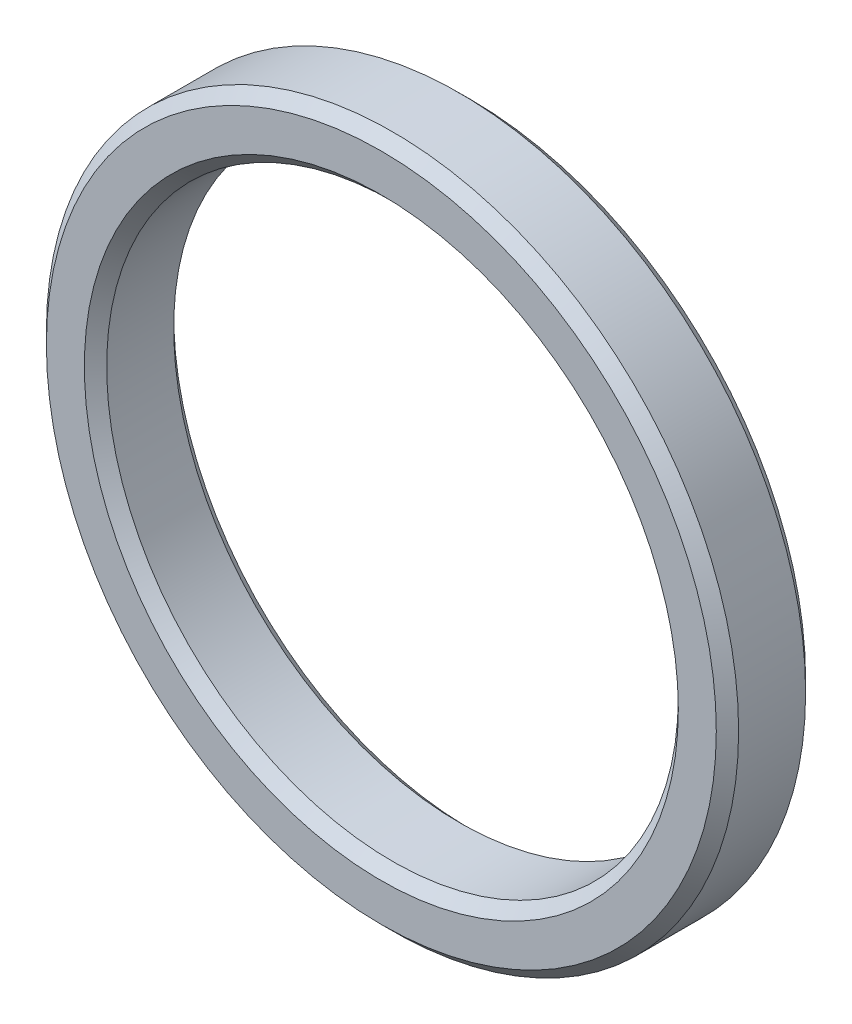
from build123d import *

# Parameters (mm, degrees)
SKETCH1_R           = 15.5
SKETCH1_R_2         = 12.8
BOSS_EXTRUDE1_DEPTH = 4
CHAMFER1_SIZE       = 0.5


with BuildPart() as part:
    # Sketch1 → Boss-Extrude1 (new body)
    with BuildSketch(Plane.XY):
        Circle(SKETCH1_R)
        Circle(SKETCH1_R_2, mode=Mode.SUBTRACT)
    extrude(amount=BOSS_EXTRUDE1_DEPTH)

    # Chamfer1
    chamfer1_edges = [part.edges().sort_by_distance(p)[0] for p in [
        (-15.5, 0, 0),
        (-15.5, 0, 4),
        (-12.8, 0, 0),
        (-12.8, 0, 4),
    ]]
    chamfer(chamfer1_edges, length=CHAMFER1_SIZE)


solid = part.part
